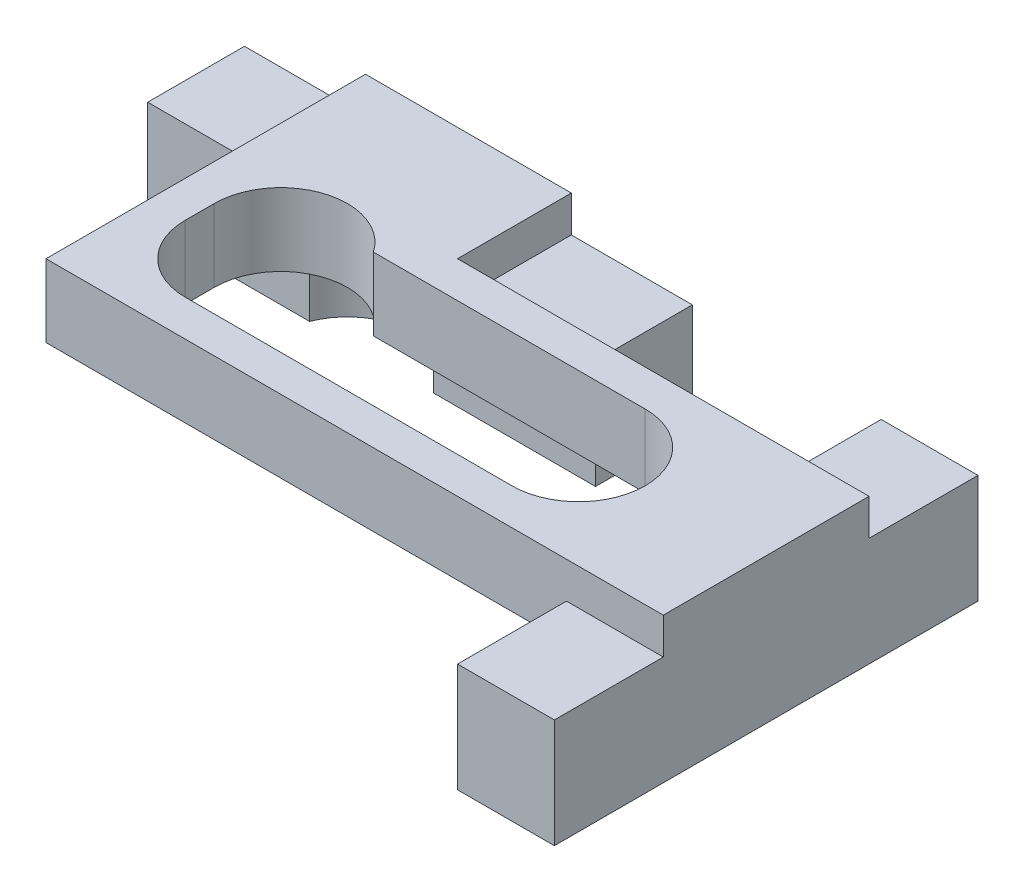
from build123d import *

# Parameters (mm, degrees)
RESSALTO_EXTRUS_O1_DEPTH = 4
ESBO_O3_W                = 8.5
ESBO_O3_H                = 3
RESSALTO_EXTRUS_O2_DEPTH = 9.2
ESBO_O4_W                = 8.5
ESBO_O4_H                = 3
RESSALTO_EXTRUS_O3_DEPTH = 13
RESSALTO_EXTRUS_O6_DEPTH = 4
CORTE_EXTRUS_O3_DEPTH    = 7
ESBO_O9_W                = 5
ESBO_O9_H                = 4
RESSALTO_EXTRUS_O7_DEPTH = 1.5
ESBO_O10_R               = 2.75
CORTE_EXTRUS_O4_DEPTH    = 3


with BuildPart() as part:
    # Esboço1 → Ressalto-extrusão1 (new body)
    with BuildSketch(Plane.XY):
        Polygon((9.25, 0), (-9.25, 0), (-9.25, 3), (-4.25, 3), (-4.25, 6), (4.25, 6), (4.25, 3), (9.25, 3), align=None)
    extrude(amount=RESSALTO_EXTRUS_O1_DEPTH)

    # Esboço3 → Ressalto-extrusão2 (add)
    with BuildSketch(Plane.XY.offset(4)):
        with Locations((0, 4.5)):
            Rectangle(ESBO_O3_W, ESBO_O3_H)
    extrude(amount=RESSALTO_EXTRUS_O2_DEPTH)

    # Esboço4 → Ressalto-extrusão3 (add)
    with BuildSketch(Plane(origin=(4.25, 0, 0), x_dir=(0, 0, -1), z_dir=(1, 0, 0))):
        with Locations((-8.95, 4.5)):
            Rectangle(ESBO_O4_W, ESBO_O4_H)
    extrude(amount=RESSALTO_EXTRUS_O3_DEPTH)

    # Esboço5 → Ressalto-extrusão6 (add)
    with BuildSketch(Plane(origin=(17.25, 0, 0), x_dir=(0, 0, -1), z_dir=(1, 0, 0))):
        Polygon((-17.7, 0), (-17.7, 4.5), (-13.2, 4.5), (-13.2, 6), (-4.7, 6), (-4.7, 4.5), (-0.2, 4.5), (-0.2, 0), align=None)
    extrude(amount=RESSALTO_EXTRUS_O6_DEPTH)

    # Esboço8 → Corte-extrusão3 (cut, through all)
    with BuildSketch(Plane(origin=(0, 6, 0), x_dir=(1, 0, 0), z_dir=(0, 1, 0))):
        with BuildLine():
            Line((13.5, -6.2), (2.271563338, -6.2))
            ThreePointArc((2.271563338, -6.2), (-0.81107978, -5.122330007), (-2.75, -7.75))
            Line((-2.75, -7.75), (-2.75, -8.95))
            ThreePointArc((-2.75, -8.95), (-1.944543648, -10.894543648), (0, -11.7))
            Line((0, -11.7), (13.5, -11.7))
            ThreePointArc((13.5, -11.7), (16.25, -8.95), (13.5, -6.2))
        make_face()
    extrude(amount=-CORTE_EXTRUS_O3_DEPTH, mode=Mode.SUBTRACT)

    # Esboço9 → Ressalto-extrusão7 (add)
    with BuildSketch(Plane(origin=(0, 3, 0), x_dir=(1, 0, 0), z_dir=(0, 1, 0))):
        with Locations((-6.75, -2)):
            Rectangle(ESBO_O9_W, ESBO_O9_H)
        with Locations((6.75, -2)):
            Rectangle(ESBO_O9_W, ESBO_O9_H)
    extrude(amount=RESSALTO_EXTRUS_O7_DEPTH)

    # Esboço10 → Corte-extrusão4 (cut)
    with BuildSketch(Plane.XZ):
        with Locations((0, 5)):
            Circle(ESBO_O10_R)
        with Locations((16.25, 8.95)):
            Circle(ESBO_O10_R)
    extrude(amount=-CORTE_EXTRUS_O4_DEPTH, mode=Mode.SUBTRACT)


solid = part.part
